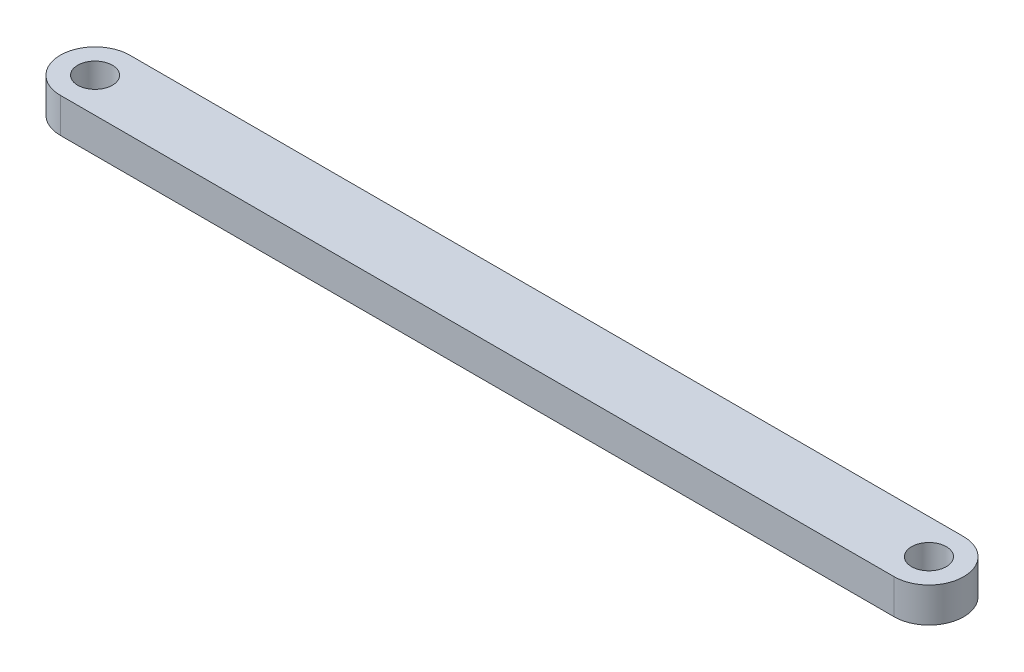
from build123d import *

# Parameters (mm, degrees)
SKETCH2_R           = 2.5
BOSS_EXTRUDE1_DEPTH = 5


with BuildPart() as part:
    # Sketch2 → Boss-Extrude1 (new body)
    with BuildSketch(Plane(origin=(0, 0, 0), x_dir=(1, 0, 0), z_dir=(0, 1, 0))):
        with BuildLine():
            Line((60, -5), (-60, -5))
            ThreePointArc((-60, -5), (-65, 0), (-60, 5))
            Line((-60, 5), (60, 5))
            ThreePointArc((60, 5), (65, 0), (60, -5))
        make_face()
        with Locations((60, 0)):
            Circle(SKETCH2_R, mode=Mode.SUBTRACT)
        with Locations((-60, 0)):
            Circle(SKETCH2_R, mode=Mode.SUBTRACT)
    extrude(amount=BOSS_EXTRUDE1_DEPTH)


solid = part.part
